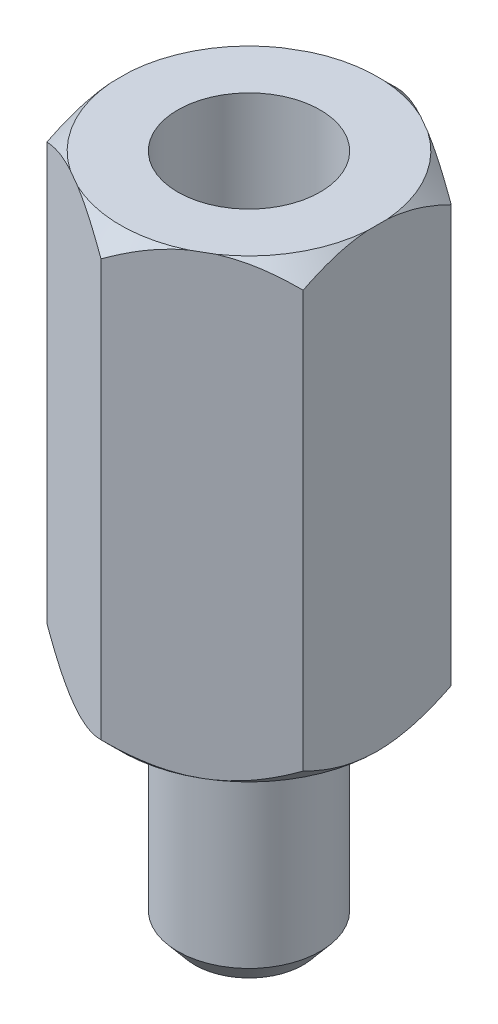
from build123d import *

# Parameters (mm, degrees)
SKETCH1_R           = 1.25
BOSS_EXTRUDE1_DEPTH = 3.9
BOSS_EXTRUDE2_DEPTH = 8
SKETCH4_R           = 1.25
CUT_EXTRUDE1_DEPTH  = 4.8
SKETCH5_OUTSIDE_W   = 35.048
SKETCH5_OUTSIDE_H   = 35.744
SKETCH5_OUTSIDE_R   = 2.257033445
CUT_EXTRUDE2_DEPTH  = 12.9
CUT_EXTRUDE2_TAPER  = 45
SKETCH6_OUTSIDE_W   = 27.248
SKETCH6_OUTSIDE_H   = 27.944
SKETCH6_OUTSIDE_R   = 2.25
CUT_EXTRUDE3_DEPTH  = 9
CUT_EXTRUDE3_TAPER  = 45
CHAMFER1_SIZE       = 0.3
CHAMFER1_SIZE2      = 0.357526078


with BuildPart() as part:
    # Sketch1 → Boss-Extrude1 (new body)
    with BuildSketch(Plane(origin=(0, 0, 0), x_dir=(1, 0, 0), z_dir=(0, 1, 0))):
        Circle(SKETCH1_R)
    extrude(amount=BOSS_EXTRUDE1_DEPTH)

    # Sketch3 → Boss-Extrude2 (add)
    with BuildSketch(Plane(origin=(0, 3.9, 0), x_dir=(1, 0, 0), z_dir=(0, 1, 0))):
        Polygon((-2.25, 1.299038106), (-2.25, -1.299038106), (0, -2.598076211), (2.25, -1.299038106), (2.25, 1.299038106), (0, 2.598076211), align=None)
    extrude(amount=BOSS_EXTRUDE2_DEPTH)

    # Sketch4 → Cut-Extrude1 (cut)
    with BuildSketch(Plane(origin=(0, 11.9, 0), x_dir=(1, 0, 0), z_dir=(0, 1, 0))):
        Circle(SKETCH4_R)
    extrude(amount=-CUT_EXTRUDE1_DEPTH, mode=Mode.SUBTRACT)

    # Sketch5 outside → Cut-Extrude2 (cut, through all)
    with BuildSketch(Plane(origin=(0, 11.9, 0), x_dir=(1, 0, 0), z_dir=(0, 1, 0))):
        Rectangle(SKETCH5_OUTSIDE_W, SKETCH5_OUTSIDE_H)
        Circle(SKETCH5_OUTSIDE_R, mode=Mode.SUBTRACT)
    extrude(amount=-CUT_EXTRUDE2_DEPTH, taper=CUT_EXTRUDE2_TAPER, mode=Mode.SUBTRACT)

    # Sketch6 outside → Cut-Extrude3 (cut, through all)
    with BuildSketch(Plane.XZ.offset(-3.9)):
        Rectangle(SKETCH6_OUTSIDE_W, SKETCH6_OUTSIDE_H)
        Circle(SKETCH6_OUTSIDE_R, mode=Mode.SUBTRACT)
    extrude(amount=-CUT_EXTRUDE3_DEPTH, taper=CUT_EXTRUDE3_TAPER, mode=Mode.SUBTRACT)

    # Chamfer1
    chamfer1_edges = [part.edges().sort_by_distance(p)[0] for p in [
        (-1.25, 0, 0),
    ]]
    chamfer1_side = [part.faces().sort_by_distance(p)[0] for p in [
        (0, 0, 0),
    ]]
    chamfer(chamfer1_edges, length=CHAMFER1_SIZE, length2=CHAMFER1_SIZE2, reference=chamfer1_side[0])


solid = part.part
